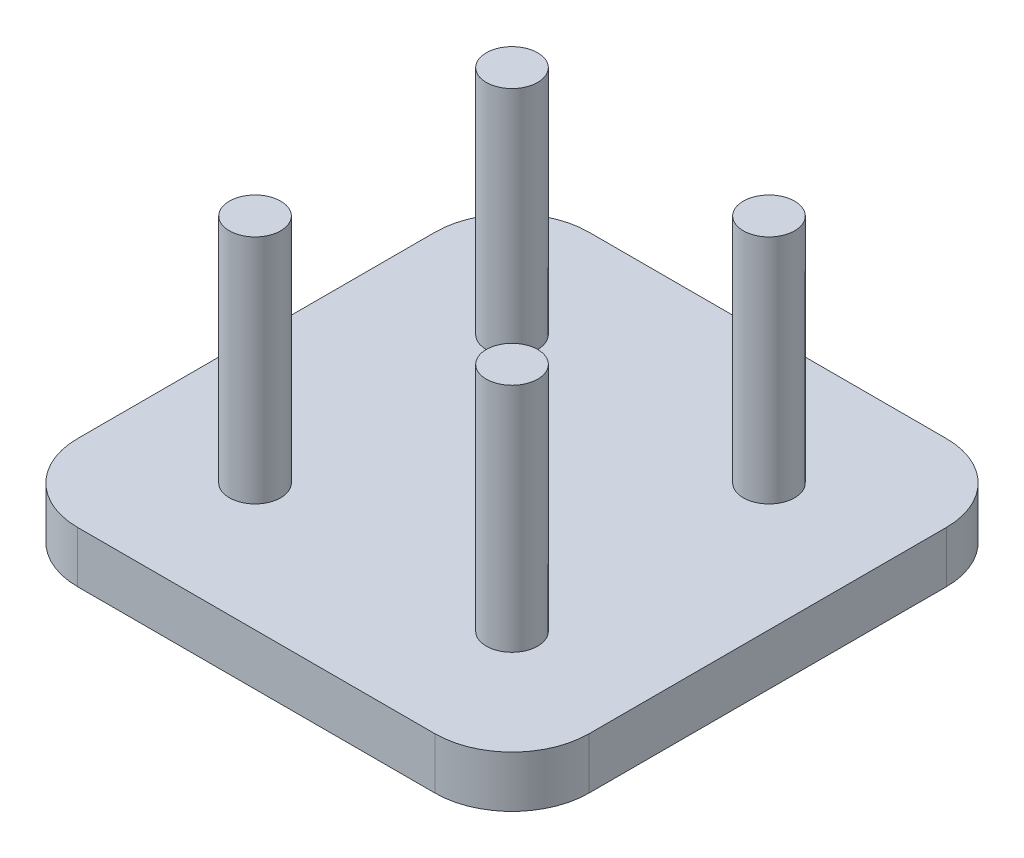
from build123d import *

# Parameters (mm, degrees)
SKETCH1_W           = 39.8
SKETCH1_H           = 39.8
BOSS_EXTRUDE1_DEPTH = 4
FILLET1_R           = 6
SKETCH2_R           = 2
BOSS_EXTRUDE2_DEPTH = 18


with BuildPart() as part:
    # Sketch1 → Boss-Extrude1 (new body)
    with BuildSketch(Plane(origin=(0, 0, 0), x_dir=(1, 0, 0), z_dir=(0, 1, 0))):
        Rectangle(SKETCH1_W, SKETCH1_H)
    extrude(amount=BOSS_EXTRUDE1_DEPTH)

    # Fillet1
    fillet1_edges = [part.edges().sort_by_distance(p)[0] for p in [
        (19.9, 2, 19.9),
        (-19.9, 2, 19.9),
        (-19.9, 2, -19.9),
        (19.9, 2, -19.9),
    ]]
    fillet(fillet1_edges, radius=FILLET1_R)

    # Sketch2 → Boss-Extrude2 (add)
    with BuildSketch(Plane(origin=(0, 4, 0), x_dir=(1, 0, 0), z_dir=(0, 1, 0))):
        with Locations((-10, 10)):
            Circle(SKETCH2_R)
        with Locations((10, 10)):
            Circle(SKETCH2_R)
        with Locations((10, -10)):
            Circle(SKETCH2_R)
        with Locations((-10, -10)):
            Circle(SKETCH2_R)
    extrude(amount=BOSS_EXTRUDE2_DEPTH)


solid = part.part
